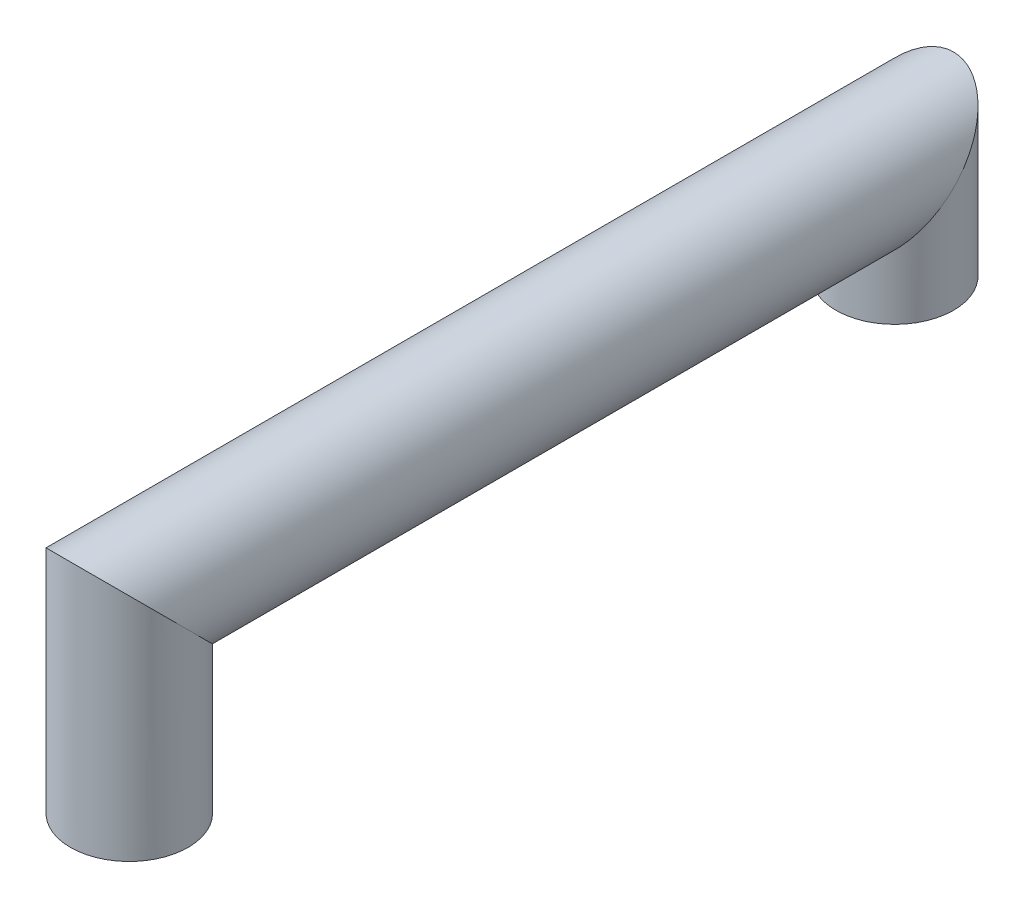
from build123d import *

# Parameters (mm, degrees)
SKETCH1_R = 5


with BuildPart() as part:
    # Sweep1: sweep along a path in Sketch2
    with BuildLine(Plane(origin=(0, 0, 0), x_dir=(0, 0, -1), z_dir=(1, 0, 0))) as sweep1_path:
        Line((0, 0), (0, 16))
        Line((0, 16), (65, 16))
        Line((65, 16), (65, 7))
    # Sketch1 → Sweep1 (sweep)
    with BuildSketch(Plane(origin=(0, 0, 0), x_dir=(1, 0, 0), z_dir=(0, 1, 0))):
        Circle(SKETCH1_R)
    sweep(path=sweep1_path.line, transition=Transition.RIGHT)


solid = part.part
